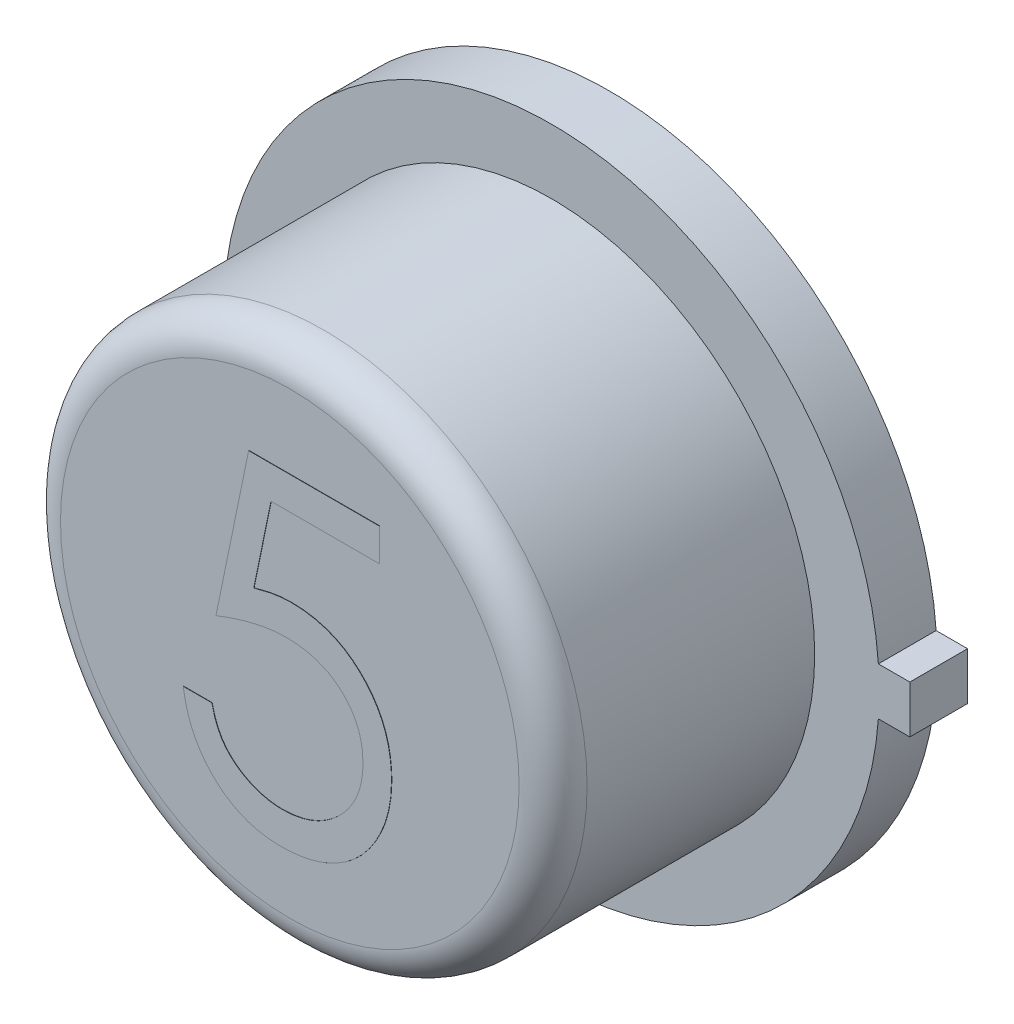
from build123d import *

# Parameters (mm, degrees)
BOSS_EXTRUDE1_DEPTH = 0.4318
SKETCH2_R           = 1.9685
BOSS_EXTRUDE2_DEPTH = 1.9558
SKETCH3_R           = 1.757566481
BOSS_EXTRUDE3_DEPTH = 0.00254
FILLET1_R           = 0.254
BOSS_EXTRUDE6_DEPTH = 0.00254


with BuildPart() as part:
    # Sketch1 → Boss-Extrude1 (new body)
    with BuildSketch(Plane.XY):
        with BuildLine():
            Line((2.6797, 0.1778), (2.4511, 0.1778))
            Line((2.4511, 0.1778), (2.44464279, 0.1778))
            ThreePointArc((2.44464279, 0.1778), (-2.4511, 0), (2.44464279, -0.1778))
            Line((2.44464279, -0.1778), (2.4511, -0.1778))
            Line((2.4511, -0.1778), (2.6797, -0.1778))
            Line((2.6797, -0.1778), (2.6797, 0.1778))
        make_face()
    extrude(amount=BOSS_EXTRUDE1_DEPTH)

    # Sketch2 → Boss-Extrude2 (add)
    with BuildSketch(Plane.XY.offset(0.4318)):
        Circle(SKETCH2_R)
    extrude(amount=BOSS_EXTRUDE2_DEPTH)

    # Sketch3 → Boss-Extrude3 (add)
    with BuildSketch(Plane(origin=(0, 0, 0), x_dir=(-1, 0, 0), z_dir=(0, 0, -1))):
        Circle(SKETCH3_R)
    extrude(amount=BOSS_EXTRUDE3_DEPTH)

    # Fillet1
    fillet1_edges = [part.edges().sort_by_distance(p)[0] for p in [
        (-1.9685, 0, 2.3876),
    ]]
    fillet(fillet1_edges, radius=FILLET1_R)

    # Sketch4 → Boss-Extrude6 (add)
    with BuildSketch(Plane.XY.offset(2.3876)):
        with BuildLine():
            Line((0.671634615, 1.163108793), (0.671634615, 0.918878024))
            Line((0.671634615, 0.918878024), (-0.138333834, 0.918878024))
            Line((-0.138333834, 0.918878024), (-0.266650391, 0.292559664))
            add(Edge.make_bspline(
                [(-0.266650391, 0.292559664), (-0.241439162, 0.299519903), (-0.192596393, 0.313004264), (-0.120505845, 0.327976047), (-0.052067221, 0.337001287), (-0.007656656, 0.338233625), (0.013833383, 0.338829947)],
                knots=[0, 0, 0, 0, 7.8447e-05, 0.000151978, 0.000220729, 0.000285189, 0.000285189, 0.000285189, 0.000285189], degree=3))
            add(Edge.make_bspline(
                [(0.013833383, 0.338829947), (0.040424285, 0.338254409), (0.092708641, 0.337122756), (0.169207282, 0.326256194), (0.242231982, 0.309152074), (0.311630023, 0.285257576), (0.377529791, 0.254702918), (0.439324971, 0.216534923), (0.497943123, 0.171948853), (0.552332637, 0.120687336), (0.601675068, 0.064271022), (0.645058715, 0.003611828), (0.68190862, -0.060700743), (0.711545491, -0.129281157), (0.735211261, -0.201371224), (0.750962886, -0.277729463), (0.761451754, -0.35763613), (0.762623592, -0.412271918), (0.763221154, -0.440132643)],
                knots=[0, 0, 0, 0, 7.9731e-05, 0.000156771, 0.000231283, 0.000304447, 0.000376577, 0.000448734, 0.00052191, 0.000597165, 0.000672552, 0.000746414, 0.000820549, 0.00089446, 0.000970187, 0.001047746, 0.001128035, 0.001211579, 0.001211579, 0.001211579, 0.001211579], degree=3))
            add(Edge.make_bspline(
                [(0.763221154, -0.440132643), (0.762768665, -0.45953794), (0.761869803, -0.498086286), (0.757298764, -0.555334394), (0.748497857, -0.611370536), (0.736681602, -0.666202146), (0.721344707, -0.719725415), (0.702778404, -0.772093544), (0.680057178, -0.822980589), (0.65513476, -0.872868045), (0.627072424, -0.920628101), (0.59592669, -0.965292858), (0.563020882, -1.007532342), (0.527614154, -1.046893543), (0.489377406, -1.08311781), (0.448773714, -1.116420123), (0.406127078, -1.147363671), (0.360777708, -1.174692389), (0.313736126, -1.199840401), (0.264322999, -1.220471236), (0.21366313, -1.238916077), (0.161027384, -1.253618274), (0.106534987, -1.265138458), (0.050096113, -1.272962974), (-0.007993236, -1.278661943), (-0.047368914, -1.279018693), (-0.067258864, -1.279198899)],
                knots=[0, 0, 0, 0, 5.8227e-05, 0.000115667, 0.000172134, 0.000228272, 0.000283835, 0.000339058, 0.000394805, 0.00045091, 0.000506295, 0.00056081, 0.000614153, 0.000666841, 0.000719477, 0.000772002, 0.000824293, 0.000877388, 0.00093073, 0.000984158, 0.001037872, 0.001092387, 0.001147959, 0.001204828, 0.001263259, 0.001322903, 0.001322903, 0.001322903, 0.001322903], degree=3))
            add(Edge.make_bspline(
                [(-0.067258864, -1.279198899), (-0.090985762, -1.278728883), (-0.137665631, -1.277804181), (-0.206055517, -1.268130533), (-0.271855989, -1.254275797), (-0.334537362, -1.233432192), (-0.394661382, -1.207315121), (-0.451418624, -1.174306798), (-0.50625934, -1.136901372), (-0.556954136, -1.09275956), (-0.604004992, -1.044511569), (-0.646123527, -0.992152888), (-0.68363405, -0.936547679), (-0.715935875, -0.877425899), (-0.743488993, -0.814942898), (-0.765134547, -0.748864571), (-0.782604999, -0.679536176), (-0.789996005, -0.631806734), (-0.79375, -0.607564284)],
                knots=[0, 0, 0, 0, 7.1133e-05, 0.000139945, 0.000206844, 0.000272613, 0.000337757, 0.000403135, 0.000469296, 0.000536609, 0.000604413, 0.000671238, 0.000737917, 0.000805377, 0.000873088, 0.000942477, 0.001013743, 0.001087302, 0.001087302, 0.001087302, 0.001087302], degree=3))
            Line((-0.79375, -0.607564284), (-0.580048077, -0.607564284))
            add(Edge.make_bspline(
                [(-0.580048077, -0.607564284), (-0.574789898, -0.630272192), (-0.564683385, -0.673918051), (-0.542499831, -0.735239553), (-0.515376798, -0.789885311), (-0.483124911, -0.838578188), (-0.444650694, -0.881038595), (-0.400747636, -0.91887806), (-0.351525346, -0.953015068), (-0.296829238, -0.981469486), (-0.239126053, -1.005736978), (-0.178732648, -1.021896613), (-0.117293441, -1.033259185), (-0.075738335, -1.034396579), (-0.05485652, -1.03496813)],
                knots=[0, 0, 0, 0, 6.9879e-05, 0.000134311, 0.000195109, 0.000252527, 0.000308938, 0.000366422, 0.000426096, 0.000488192, 0.000551085, 0.000613465, 0.000675418, 0.000737996, 0.000737996, 0.000737996, 0.000737996], degree=3))
            add(Edge.make_bspline(
                [(-0.05485652, -1.03496813), (-0.034474079, -1.034409708), (0.005659116, -1.03331017), (0.064721863, -1.024847199), (0.12174455, -1.011813209), (0.17616452, -0.992307468), (0.228934067, -0.968600615), (0.278718365, -0.938178394), (0.326957644, -0.903167203), (0.372152499, -0.863055639), (0.413545053, -0.818853043), (0.450118413, -0.771583602), (0.480582706, -0.721157676), (0.506255377, -0.668448263), (0.525749853, -0.612877673), (0.539657021, -0.554706338), (0.547823388, -0.493790575), (0.54894678, -0.452241634), (0.549519231, -0.431069392)],
                knots=[0, 0, 0, 0, 6.1125e-05, 0.000120355, 0.00017867, 0.0002363, 0.000293503, 0.000351914, 0.000410973, 0.000472137, 0.000532884, 0.000592419, 0.000651076, 0.000709321, 0.000768009, 0.000827362, 0.000888483, 0.000951991, 0.000951991, 0.000951991, 0.000951991], degree=3))
            add(Edge.make_bspline(
                [(0.549519231, -0.431069392), (0.54907123, -0.411967854), (0.548194331, -0.374579311), (0.541029782, -0.319879136), (0.528567699, -0.268122299), (0.511270381, -0.219058864), (0.489308787, -0.172642558), (0.462471207, -0.128825476), (0.430253984, -0.088185136), (0.393452182, -0.050702524), (0.35313555, -0.01610985), (0.308610432, 0.013379609), (0.260808589, 0.038188096), (0.210305951, 0.059597573), (0.155901261, 0.074974152), (0.09867191, 0.086518374), (0.037999899, 0.093196326), (-0.003481944, 0.094122896), (-0.024804687, 0.094599178)],
                knots=[0, 0, 0, 0, 5.7291e-05, 0.000112139, 0.000165129, 0.000216726, 0.000267935, 0.000318904, 0.000370532, 0.000423155, 0.000476292, 0.000529609, 0.000582951, 0.000637698, 0.000693852, 0.000752227, 0.000812701, 0.000876665, 0.000876665, 0.000876665, 0.000876665], degree=3))
            add(Edge.make_bspline(
                [(-0.024804687, 0.094599178), (-0.043262048, 0.094204168), (-0.081371815, 0.093388574), (-0.139830024, 0.087383404), (-0.201260642, 0.077695598), (-0.265428183, 0.064369955), (-0.33252535, 0.046931669), (-0.402410548, 0.026034839), (-0.475230715, 0.001050765), (-0.524296524, -0.017817045), (-0.549519231, -0.027516207)],
                knots=[0, 0, 0, 0, 5.5366e-05, 0.000114318, 0.000176116, 0.000241883, 0.000310838, 0.000384033, 0.000460664, 0.00054173, 0.00054173, 0.00054173, 0.00054173], degree=3))
            Line((-0.549519231, -0.027516207), (-0.305288462, 1.163108793))
            Line((-0.305288462, 1.163108793), (0.671634615, 1.163108793))
        make_face()
    extrude(amount=BOSS_EXTRUDE6_DEPTH)


solid = part.part
